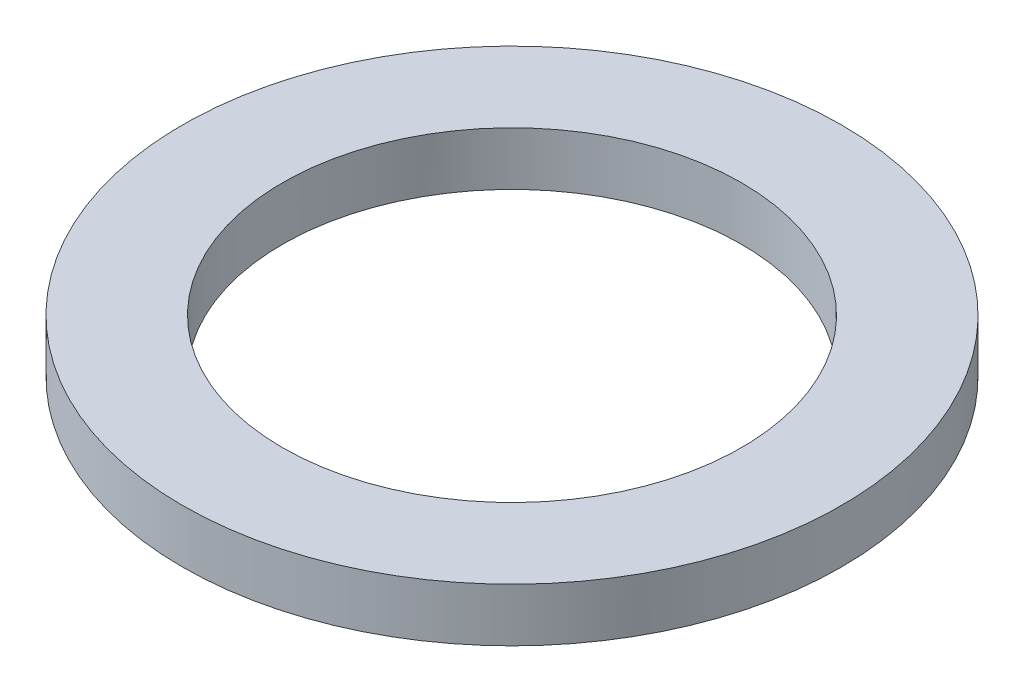
from build123d import *

# Parameters (mm, degrees)
SKETCH_1_R      = 30.874
SKETCH_1_R_2    = 21.5
EXTRUDE_1_DEPTH = 5


with BuildPart() as part:
    # Эскиз1 → Бобышка-Вытянуть1 (new body)
    with BuildSketch(Plane(origin=(0, 0, 0), x_dir=(1, 0, 0), z_dir=(0, 1, 0))):
        Circle(SKETCH_1_R)
        Circle(SKETCH_1_R_2, mode=Mode.SUBTRACT)
    extrude(amount=-EXTRUDE_1_DEPTH)


solid = part.part
